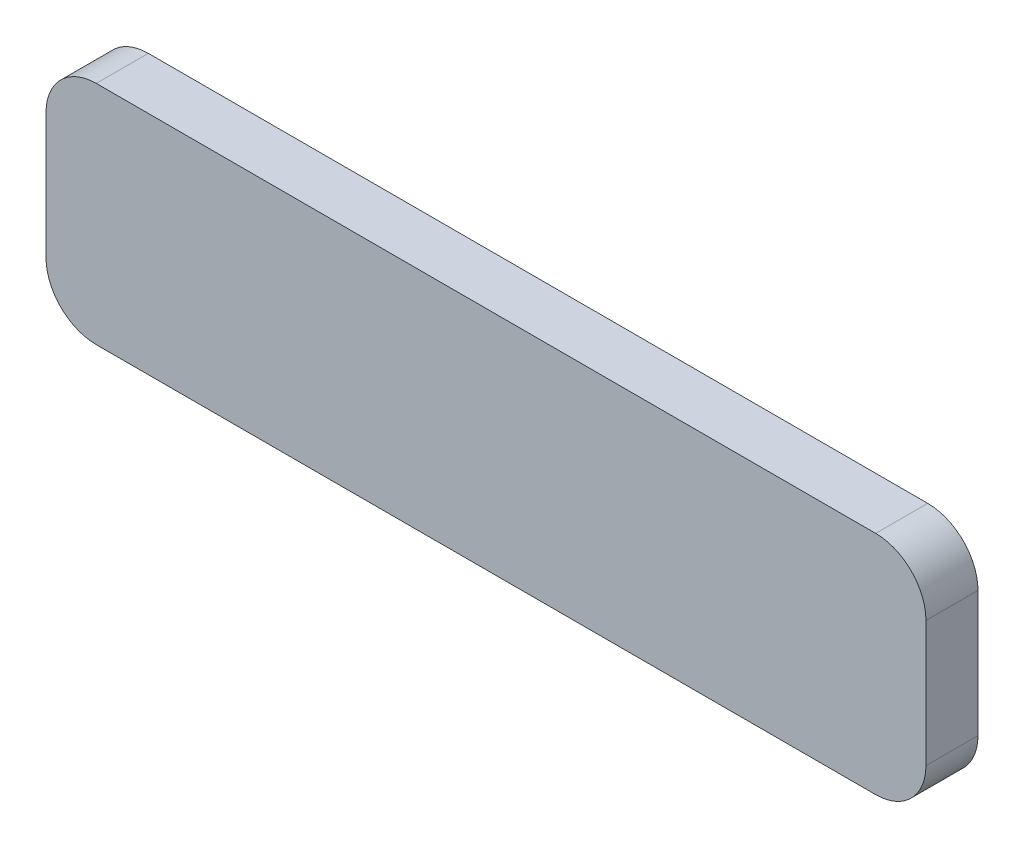
from build123d import *

# Parameters (mm, degrees)
SKETCH1_W           = 88.9
SKETCH1_H           = 22.86
BOSS_EXTRUDE1_DEPTH = 5.2578
FILLET1_R           = 5.08
FILLET2_R           = 5.08
FILLET3_R           = 5.08
FILLET4_R           = 5.08


with BuildPart() as part:
    # Sketch1 → Boss-Extrude1 (new body)
    with BuildSketch(Plane.XY):
        Rectangle(SKETCH1_W, SKETCH1_H)
    extrude(amount=BOSS_EXTRUDE1_DEPTH)

    # Fillet1
    fillet1_edges = [part.edges().sort_by_distance(p)[0] for p in [
        (-44.45, 11.43, 2.6289),
    ]]
    fillet(fillet1_edges, radius=FILLET1_R)

    # Fillet2
    fillet2_edges = [part.edges().sort_by_distance(p)[0] for p in [
        (44.45, 11.43, 2.6289),
    ]]
    fillet(fillet2_edges, radius=FILLET2_R)

    # Fillet3
    fillet3_edges = [part.edges().sort_by_distance(p)[0] for p in [
        (44.45, -11.43, 2.6289),
    ]]
    fillet(fillet3_edges, radius=FILLET3_R)

    # Fillet4
    fillet4_edges = [part.edges().sort_by_distance(p)[0] for p in [
        (-44.45, -11.43, 2.6289),
    ]]
    fillet(fillet4_edges, radius=FILLET4_R)


solid = part.part
